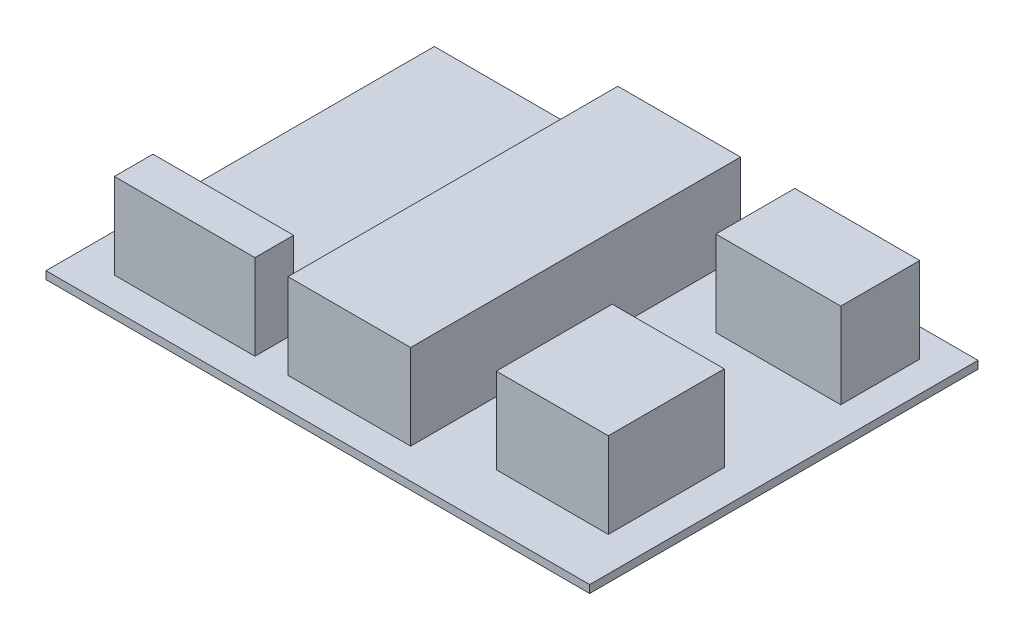
from build123d import *

# Parameters (mm, degrees)
SKETCH1_W           = 70
SKETCH1_H           = 50
BOSS_EXTRUDE1_DEPTH = 1
SKETCH2_W           = 15.79200929
SKETCH2_H           = 42.472572931
SKETCH2_W_2         = 16.080447816
SKETCH2_H_2         = 10.167458036
SKETCH2_W_3         = 14.421926292
SKETCH2_H_3         = 14.926693712
SKETCH2_W_4         = 18.099517497
SKETCH2_H_4         = 4.975564571
BOSS_EXTRUDE2_DEPTH = 12


with BuildPart() as part:
    # Sketch1 → Boss-Extrude1 (new body)
    with BuildSketch(Plane(origin=(0, 0, 0), x_dir=(1, 0, 0), z_dir=(0, 1, 0))):
        with Locations((3.189448441, 12.661870504)):
            Rectangle(SKETCH1_W, SKETCH1_H)
    extrude(amount=BOSS_EXTRUDE1_DEPTH)

    # Sketch2 → Boss-Extrude2 (add)
    with BuildSketch(Plane(origin=(0, 0, 0), x_dir=(1, 0, 0), z_dir=(0, 1, 0))):
        with Locations((3.333667704, 12.806089767)):
            Rectangle(SKETCH2_W, SKETCH2_H)
        with Locations((26.264530509, 28.958647214)):
            Rectangle(SKETCH2_W_2, SKETCH2_H_2)
        with Locations((26.58902385, 1.917535416)):
            Rectangle(SKETCH2_W_3, SKETCH2_H_3)
        with Locations((-17.866563946, -5.942414413)):
            Rectangle(SKETCH2_W_4, SKETCH2_H_4)
    extrude(amount=BOSS_EXTRUDE2_DEPTH)


solid = part.part
